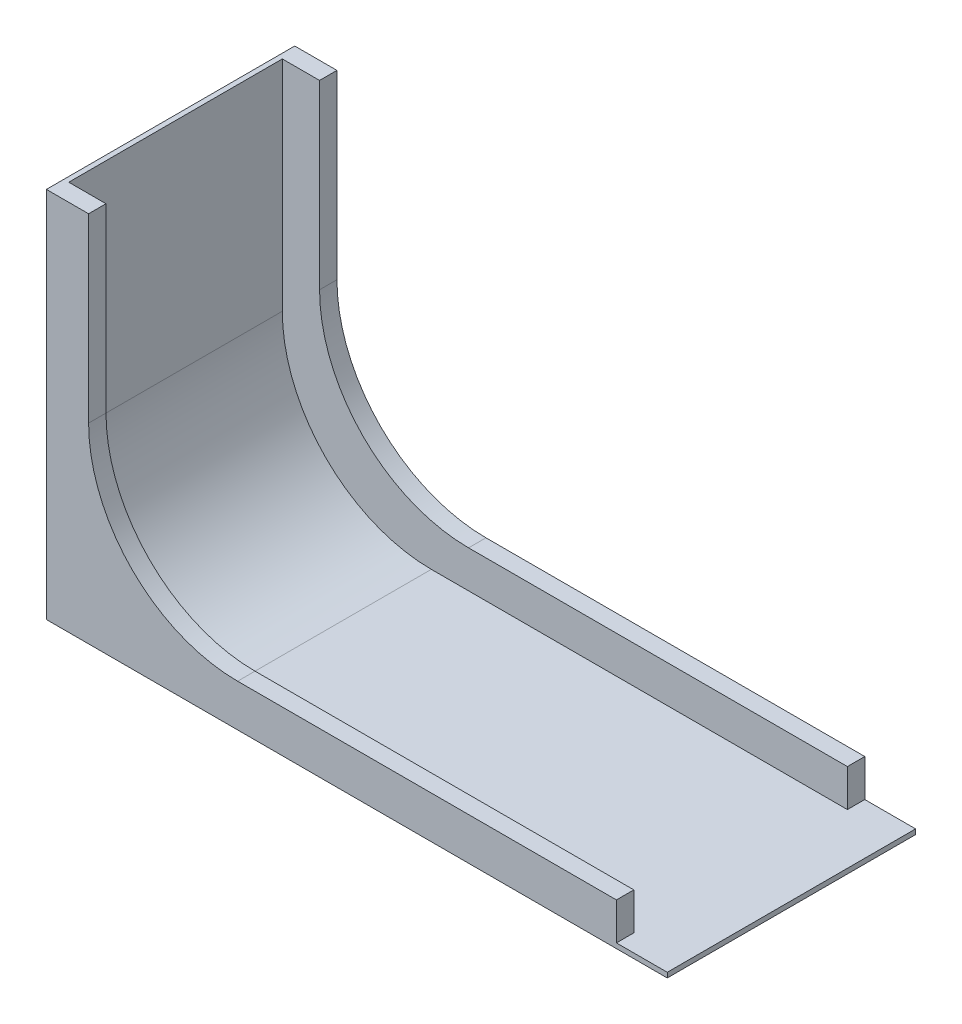
from build123d import *

# Parameters (mm, degrees)
BOSS_EXTRUDE1_DEPTH = 100
SKETCH5_W           = 227.526539108
SKETCH5_H           = 7
BOSS_EXTRUDE4_DEPTH = 15
SKETCH6_W           = 7
SKETCH6_H           = 133
BOSS_EXTRUDE5_DEPTH = 15
FILLET2_R           = 60


with BuildPart() as part:
    # Sketch2 → Boss-Extrude1 (new body)
    with BuildSketch(Plane.XY):
        Polygon((-0.232315645, -1.10373444), (-50.232315645, -1.10373444), (-50.232315645, 148.89626556), (-48.232315645, 148.89626556), (-48.232315645, 0.89626556), (-3.293749688, 0.89626556), (-0.232315645, 0.89626556), (199.767684355, 0.89626556), (199.767684355, -1.10373444), align=None)
    extrude(amount=BOSS_EXTRUDE1_DEPTH)

    # Sketch5 → Boss-Extrude4 (add)
    with BuildSketch(Plane(origin=(0, 0.89626556, 0), x_dir=(1, 0, 0), z_dir=(0, 1, 0))):
        with Locations((65.530953909, -3.5)):
            Rectangle(SKETCH5_W, SKETCH5_H)
        with Locations((65.530953909, -96.5)):
            Rectangle(SKETCH5_W, SKETCH5_H)
    extrude(amount=BOSS_EXTRUDE4_DEPTH)

    # Sketch6 → Boss-Extrude5 (add)
    with BuildSketch(Plane(origin=(-48.232315645, 0, 0), x_dir=(0, 0, -1), z_dir=(1, 0, 0))):
        with Locations((-96.5, 82.39626556)):
            Rectangle(SKETCH6_W, SKETCH6_H)
        with Locations((-3.5, 82.39626556)):
            Rectangle(SKETCH6_W, SKETCH6_H)
    extrude(amount=BOSS_EXTRUDE5_DEPTH)

    # Fillet2
    fillet2_edges = [part.edges().sort_by_distance(p)[0] for p in [
        (-48.232315645, 0.89626556, 50),
        (-33.232315645, 15.89626556, 96.5),
        (-33.232315645, 15.89626556, 3.5),
    ]]
    fillet(fillet2_edges, radius=FILLET2_R)


solid = part.part
